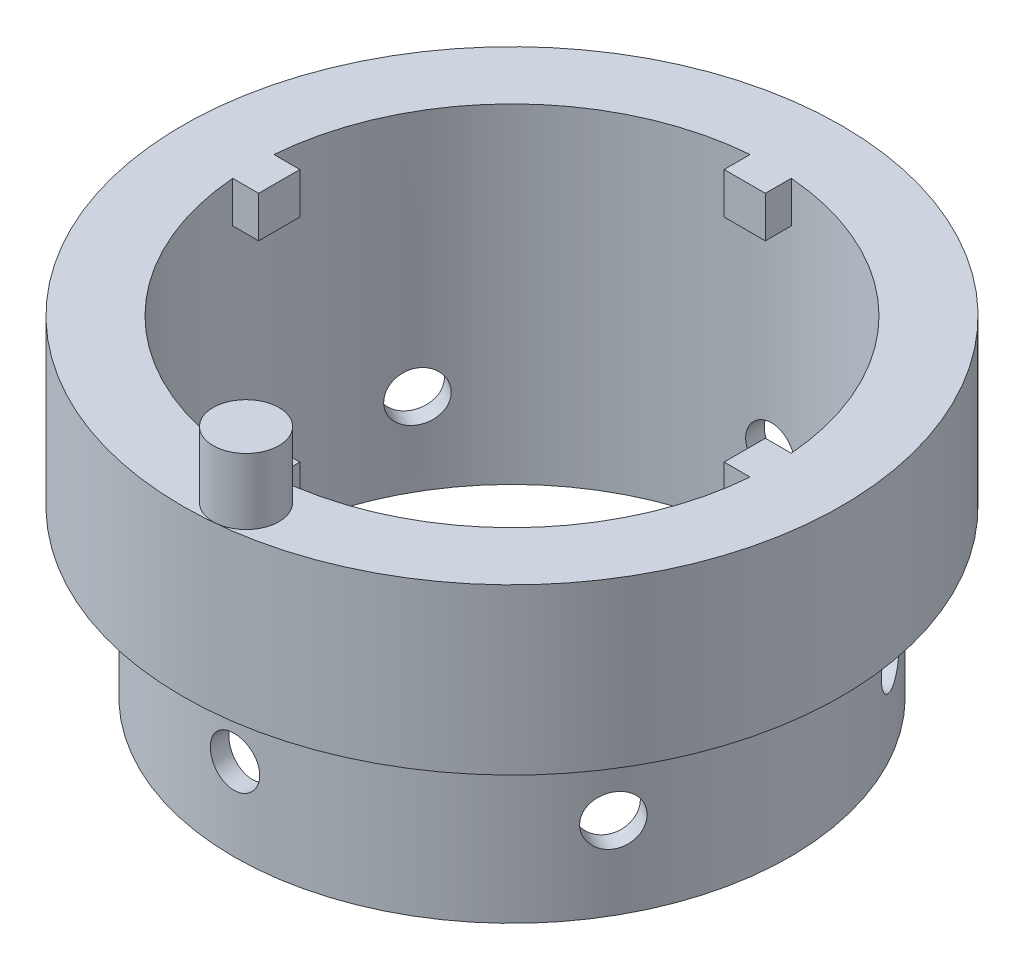
from build123d import *

# Parameters (mm, degrees)
SKETCH8_R           = 3.81
CUT_EXTRUDE2_DEPTH  = 10.16
CIRPATTERN1_COUNT   = 6
SKETCH10_R          = 40.005
CUT_EXTRUDE4_DEPTH  = 125.434078974
SKETCH16_R          = 5.079288484
BOSS_EXTRUDE1_DEPTH = 10.16
SKETCH17_W          = 6.35
SKETCH17_H          = 6.35
BOSS_EXTRUDE2_DEPTH = 4.7625
CIRPATTERN2_COUNT   = 4


with BuildPart() as part:
    # Sketch1 → Revolve1 (revolve)
    with BuildSketch(Plane(origin=(0, 0, 0), x_dir=(0, 0, -1), z_dir=(1, 0, 0))):
        Polygon((0, 0), (0, -25.4), (7.9375, -25.4), (7.9375, -50.8), (12.7, -50.8), (12.7, 0), align=None)
    revolve(axis=Axis((0, 24.668312757, -50.8), (0, -1, 0)))

    # Sketch8 → Cut-Extrude2 (cut, symmetric)
    with BuildSketch(Plane.XY.offset(-8.282540139)):
        with Locations((0, -38.1)):
            Circle(SKETCH8_R)
    cut_extrude2 = extrude(amount=CUT_EXTRUDE2_DEPTH, both=True, mode=Mode.SUBTRACT)

    # CirPattern1: Cut-Extrude2 ×6 about axis
    cirpattern1_axis = Axis((0, 24.668312757, -50.8), (0, 1, 0))
    for i in range(1, CIRPATTERN1_COUNT):
        add(cut_extrude2.rotate(cirpattern1_axis, i * 360 / CIRPATTERN1_COUNT), mode=Mode.SUBTRACT)

    # Sketch10 → Cut-Extrude4 (cut, through all)
    with BuildSketch(Plane.XZ.offset(50.8)):
        with Locations((0, -50.8)):
            Circle(SKETCH10_R)
    extrude(amount=-CUT_EXTRUDE4_DEPTH, mode=Mode.SUBTRACT)

    # Sketch16 → Boss-Extrude1 (add)
    with BuildSketch(Plane(origin=(0, 0, 0), x_dir=(1, 0, 0), z_dir=(0, 1, 0))):
        with Locations((4.452646476, 5.350182374)):
            Circle(SKETCH16_R)
    extrude(amount=BOSS_EXTRUDE1_DEPTH)

    # Sketch17 → Boss-Extrude2 (add)
    with BuildSketch(Plane.XY.offset(-10.16)):
        with Locations((0, -3.175)):
            Rectangle(SKETCH17_W, SKETCH17_H)
    boss_extrude2 = extrude(amount=-BOSS_EXTRUDE2_DEPTH)

    # CirPattern2: Boss-Extrude2 ×4 about axis
    cirpattern2_axis = Axis((0, 0, -50.8), (0, -1, 0))
    for i in range(1, CIRPATTERN2_COUNT):
        add(boss_extrude2.rotate(cirpattern2_axis, i * 360 / CIRPATTERN2_COUNT))


solid = part.part
